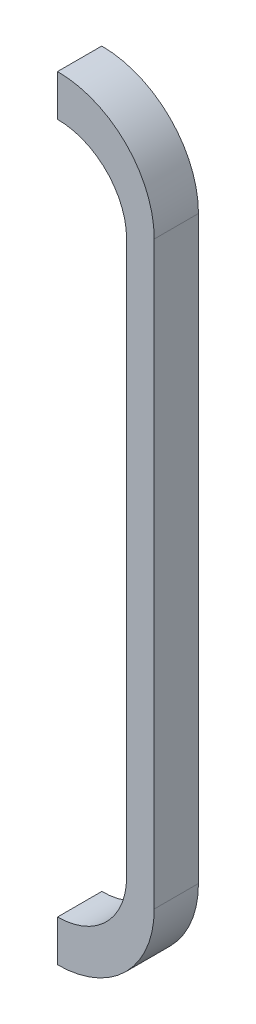
from build123d import *

# Parameters (mm, degrees)
BOSS_EXTRUDE1_DEPTH = 1.6


with BuildPart() as part:
    # Sketch1 → Boss-Extrude1 (new body)
    with BuildSketch(Plane.XY):
        with BuildLine():
            Line((13.5, 10.5), (13.5, -10.5))
            ThreePointArc((13.5, -10.5), (12.474873734, -12.974873734), (10, -14))
            Line((10, -14), (10, -12.5))
            ThreePointArc((10, -12.5), (11.767766953, -11.767766953), (12.5, -10))
            Line((12.5, -10), (12.5, 10))
            ThreePointArc((12.5, 10), (11.767766953, 11.767766953), (10, 12.5))
            Line((10, 12.5), (10, 14))
            ThreePointArc((10, 14), (12.474873734, 12.974873734), (13.5, 10.5))
        make_face()
    extrude(amount=BOSS_EXTRUDE1_DEPTH)


solid = part.part
